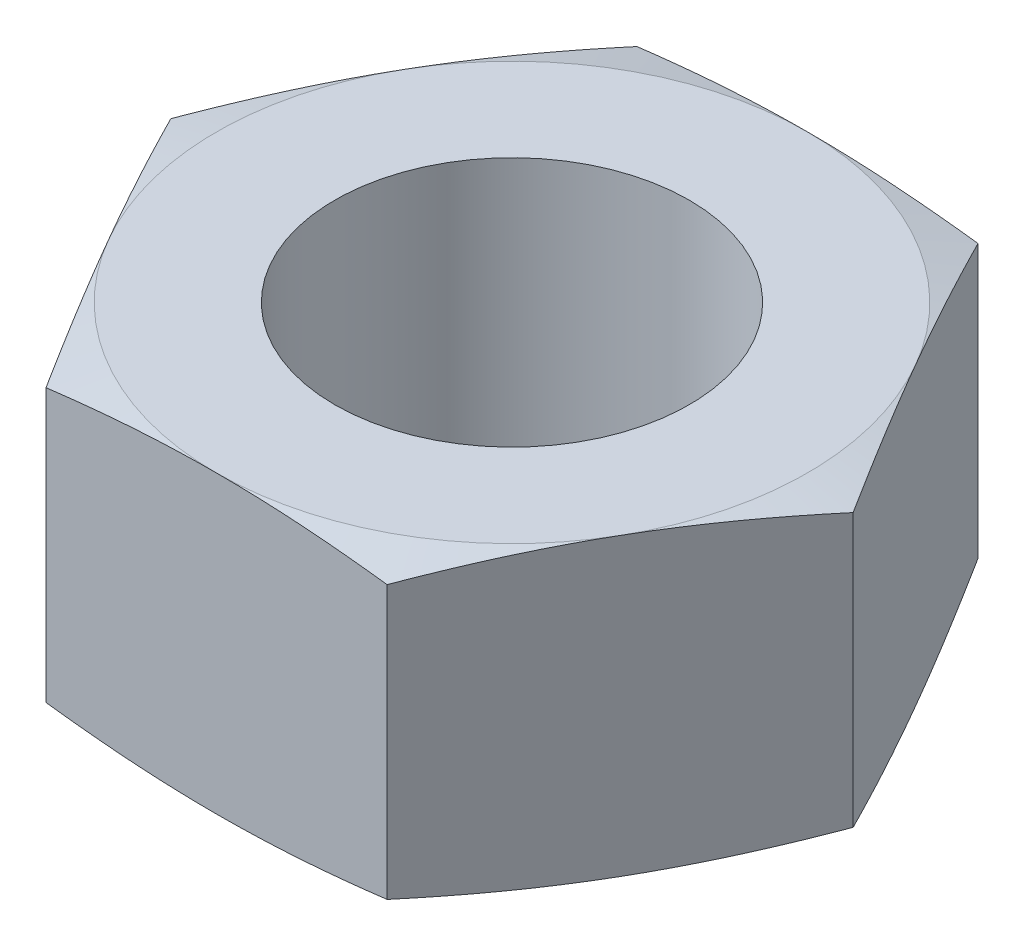
from build123d import *

# Parameters (mm, degrees)
SKETCH1_R           = 3
BOSS_EXTRUDE1_DEPTH = 5
SKETCH2_OUTSIDE_W   = 18.366
SKETCH2_OUTSIDE_H   = 16.818
SKETCH2_OUTSIDE_R   = 5
CUT_EXTRUDE2_DEPTH  = 0.2
CUT_EXTRUDE2_TAPER  = 76
SKETCH3_OUTSIDE_W   = 18.366
SKETCH3_OUTSIDE_H   = 16.818
SKETCH3_OUTSIDE_R   = 5
CUT_EXTRUDE3_DEPTH  = 0.2
CUT_EXTRUDE3_TAPER  = 76


with BuildPart() as part:
    # Sketch1 → Boss-Extrude1 (new body)
    with BuildSketch(Plane(origin=(0, 0, 0), x_dir=(1, 0, 0), z_dir=(0, 1, 0))):
        Polygon((5.773502692, 0), (2.886751346, 5), (-2.886751346, 5), (-5.773502692, 0), (-2.886751346, -5), (2.886751346, -5), align=None)
        Circle(SKETCH1_R, mode=Mode.SUBTRACT)
    extrude(amount=BOSS_EXTRUDE1_DEPTH)

    # Sketch2 outside → Cut-Extrude2 (cut)
    with BuildSketch(Plane(origin=(0, 5, 0), x_dir=(1, 0, 0), z_dir=(0, 1, 0))):
        Rectangle(SKETCH2_OUTSIDE_W, SKETCH2_OUTSIDE_H)
        Circle(SKETCH2_OUTSIDE_R, mode=Mode.SUBTRACT)
    extrude(amount=-CUT_EXTRUDE2_DEPTH, taper=CUT_EXTRUDE2_TAPER, mode=Mode.SUBTRACT)

    # Sketch3 outside → Cut-Extrude3 (cut)
    with BuildSketch(Plane.XZ):
        Rectangle(SKETCH3_OUTSIDE_W, SKETCH3_OUTSIDE_H)
        Circle(SKETCH3_OUTSIDE_R, mode=Mode.SUBTRACT)
    extrude(amount=-CUT_EXTRUDE3_DEPTH, taper=CUT_EXTRUDE3_TAPER, mode=Mode.SUBTRACT)


solid = part.part
